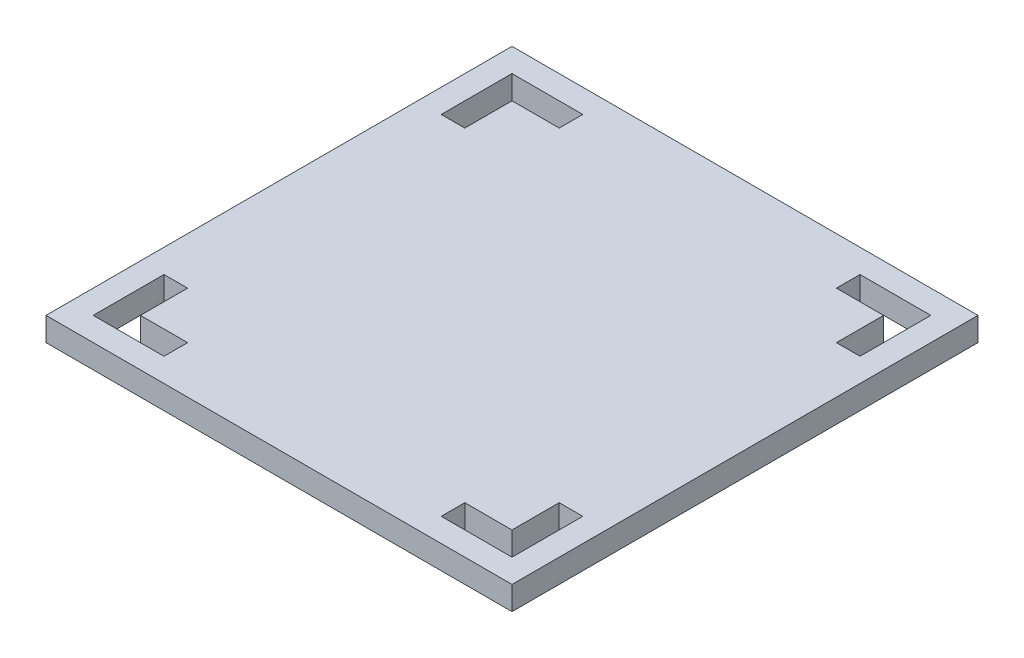
from build123d import *

# Parameters (mm, degrees)
SKETCH1_W           = 125.4
SKETCH1_H           = 125.4
BOSS_EXTRUDE1_DEPTH = 6.35
SKETCH4_W           = 6.35
SKETCH4_H           = 12.7
CUT_EXTRUDE1_DEPTH  = 89.898270512
SKETCH5_W           = 19.05
SKETCH5_H           = 6.35
CUT_EXTRUDE2_DEPTH  = 89.898270512
CIRPATTERN1_COUNT   = 4
CIRPATTERN2_COUNT   = 4


with BuildPart() as part:
    # Sketch1 → Boss-Extrude1 (new body)
    with BuildSketch(Plane(origin=(0, 0, 0), x_dir=(1, 0, 0), z_dir=(0, 1, 0))):
        Rectangle(SKETCH1_W, SKETCH1_H)
    extrude(amount=BOSS_EXTRUDE1_DEPTH)

    # Sketch4 → Cut-Extrude1 (cut, through all)
    with BuildSketch(Plane(origin=(0, 6.35, 0), x_dir=(1, 0, 0), z_dir=(0, 1, 0))):
        with Locations((-53.175, 43.65)):
            Rectangle(SKETCH4_W, SKETCH4_H)
    cut_extrude1 = extrude(amount=-CUT_EXTRUDE1_DEPTH, mode=Mode.SUBTRACT)

    # Sketch5 → Cut-Extrude2 (cut, through all)
    with BuildSketch(Plane(origin=(0, 6.35, 0), x_dir=(1, 0, 0), z_dir=(0, 1, 0))):
        with Locations((-46.825, 53.175)):
            Rectangle(SKETCH5_W, SKETCH5_H)
    cut_extrude2 = extrude(amount=-CUT_EXTRUDE2_DEPTH, mode=Mode.SUBTRACT)

    # CirPattern1: Cut-Extrude1 ×4 about axis
    cirpattern1_axis = Axis((0, 6.35, 0), (0, 1, 0))
    for i in range(1, CIRPATTERN1_COUNT):
        add(cut_extrude1.rotate(cirpattern1_axis, i * 360 / CIRPATTERN1_COUNT), mode=Mode.SUBTRACT)

    # CirPattern2: Cut-Extrude2 ×4 about axis
    cirpattern2_axis = Axis((0, 6.35, 0), (0, 1, 0))
    for i in range(1, CIRPATTERN2_COUNT):
        add(cut_extrude2.rotate(cirpattern2_axis, i * 360 / CIRPATTERN2_COUNT), mode=Mode.SUBTRACT)


solid = part.part
